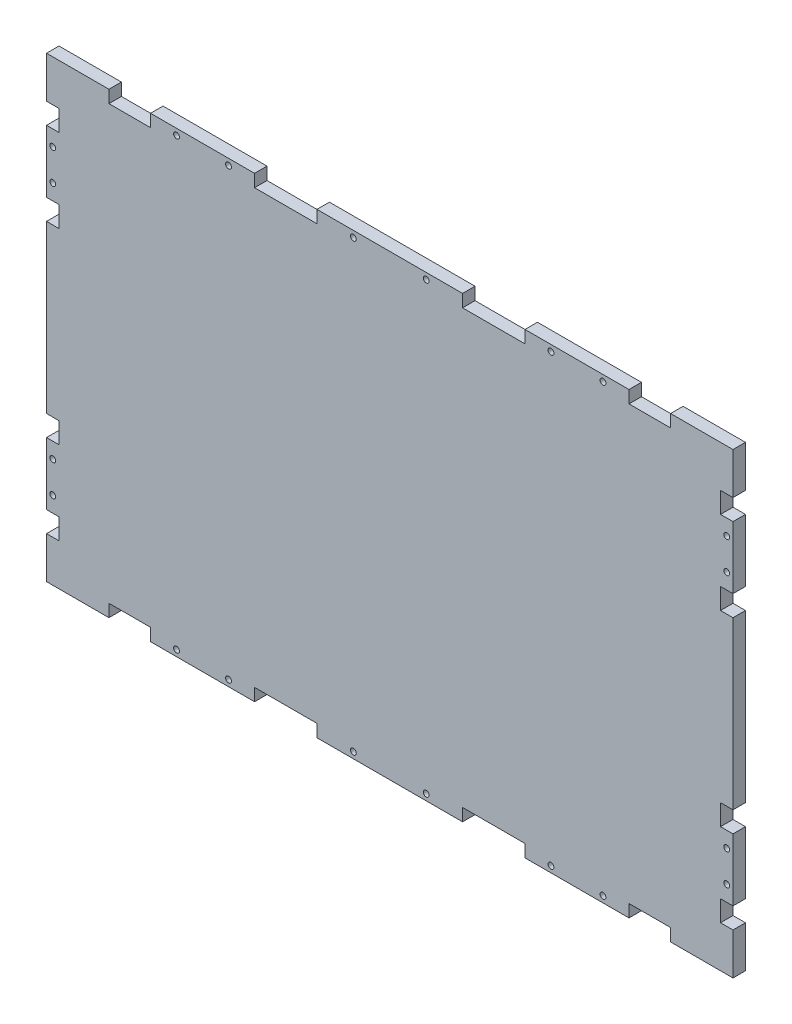
from build123d import *

# Parameters (mm, degrees)
ESQUISSE1_W             = 330
ESQUISSE1_H             = 220
BOSS_EXTRU_1_DEPTH      = 6
ESQUISSE3_W             = 20
ESQUISSE3_H             = 6
ESQUISSE3_W_2           = 30
ESQUISSE3_W_3           = 6
ESQUISSE3_H_2           = 10
ENL_V_MAT_EXTRU_2_DEPTH = 6
ESQUISSE4_R             = 1.4
ENL_V_MAT_EXTRU_3_DEPTH = 6


with BuildPart() as part:
    # Esquisse1 → Boss.-Extru.1 (new body)
    with BuildSketch(Plane.XY):
        Rectangle(ESQUISSE1_W, ESQUISSE1_H)
    extrude(amount=BOSS_EXTRU_1_DEPTH)

    # Esquisse3 → Enlèv. mat.-Extru.2 (cut)
    with BuildSketch(Plane.XY.offset(6)):
        with Locations((-125, 107)):
            Rectangle(ESQUISSE3_W, ESQUISSE3_H)
        with Locations((-50, 107)):
            Rectangle(ESQUISSE3_W_2, ESQUISSE3_H)
        with Locations((-162, 45)):
            Rectangle(ESQUISSE3_W_3, ESQUISSE3_H_2)
        with Locations((50, 107)):
            Rectangle(ESQUISSE3_W_2, ESQUISSE3_H)
        with Locations((-162, 85)):
            Rectangle(ESQUISSE3_W_3, ESQUISSE3_H_2)
        with Locations((162, 85)):
            Rectangle(ESQUISSE3_W_3, ESQUISSE3_H_2)
        with Locations((162, 45)):
            Rectangle(ESQUISSE3_W_3, ESQUISSE3_H_2)
        with Locations((125, 107)):
            Rectangle(ESQUISSE3_W, ESQUISSE3_H)
        with Locations((125, -107)):
            Rectangle(ESQUISSE3_W, ESQUISSE3_H)
        with Locations((50, -107)):
            Rectangle(ESQUISSE3_W_2, ESQUISSE3_H)
        with Locations((162, -45)):
            Rectangle(ESQUISSE3_W_3, ESQUISSE3_H_2)
        with Locations((162, -85)):
            Rectangle(ESQUISSE3_W_3, ESQUISSE3_H_2)
        with Locations((-162, -85)):
            Rectangle(ESQUISSE3_W_3, ESQUISSE3_H_2)
        with Locations((-162, -45)):
            Rectangle(ESQUISSE3_W_3, ESQUISSE3_H_2)
        with Locations((-50, -107)):
            Rectangle(ESQUISSE3_W_2, ESQUISSE3_H)
        with Locations((-125, -107)):
            Rectangle(ESQUISSE3_W, ESQUISSE3_H)
    extrude(amount=-ENL_V_MAT_EXTRU_2_DEPTH, mode=Mode.SUBTRACT)

    # Esquisse4 → Enlèv. mat.-Extru.3 (cut)
    with BuildSketch(Plane.XY.offset(6)):
        with Locations((-102.5, 107)):
            Circle(ESQUISSE4_R)
        with Locations((-77.5, 107)):
            Circle(ESQUISSE4_R)
        with Locations((-17.5, 107)):
            Circle(ESQUISSE4_R)
        with Locations((-162, 72.5)):
            Circle(ESQUISSE4_R)
        with Locations((-162, 57.5)):
            Circle(ESQUISSE4_R)
        with Locations((162, 57.5)):
            Circle(ESQUISSE4_R)
        with Locations((162, 72.5)):
            Circle(ESQUISSE4_R)
        with Locations((17.5, 107)):
            Circle(ESQUISSE4_R)
        with Locations((77.5, 107)):
            Circle(ESQUISSE4_R)
        with Locations((102.5, 107)):
            Circle(ESQUISSE4_R)
        with Locations((102.5, -107)):
            Circle(ESQUISSE4_R)
        with Locations((77.5, -107)):
            Circle(ESQUISSE4_R)
        with Locations((17.5, -107)):
            Circle(ESQUISSE4_R)
        with Locations((162, -72.5)):
            Circle(ESQUISSE4_R)
        with Locations((162, -57.5)):
            Circle(ESQUISSE4_R)
        with Locations((-162, -57.5)):
            Circle(ESQUISSE4_R)
        with Locations((-162, -72.5)):
            Circle(ESQUISSE4_R)
        with Locations((-17.5, -107)):
            Circle(ESQUISSE4_R)
        with Locations((-77.5, -107)):
            Circle(ESQUISSE4_R)
        with Locations((-102.5, -107)):
            Circle(ESQUISSE4_R)
    extrude(amount=-ENL_V_MAT_EXTRU_3_DEPTH, mode=Mode.SUBTRACT)


solid = part.part
